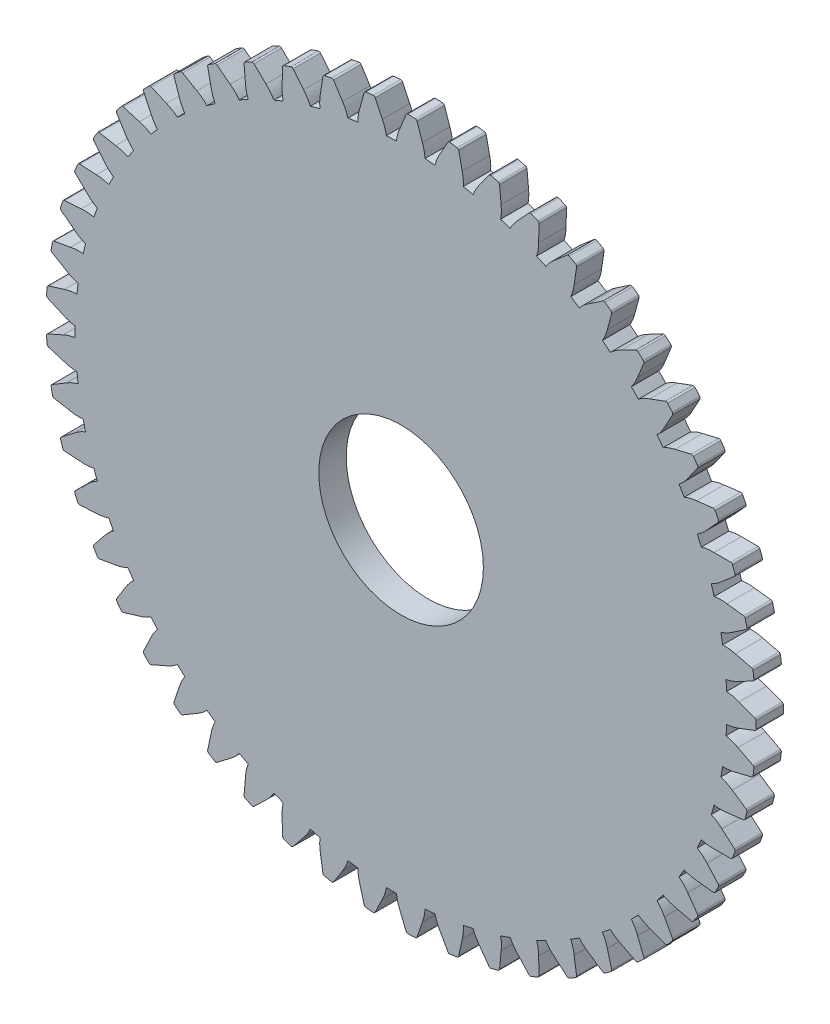
from build123d import *

# Parameters (mm, degrees)
BOSS_EXTRUDE1_DEPTH = 2
SKETCH2_R           = 6
CUT_EXTRUDE1_DEPTH  = 2


with BuildPart() as part:
    # Model → Boss-Extrude1 (new body)
    with BuildSketch(Plane.XY):
        with BuildLine():
            ThreePointArc((51.106924934, 28.354959457), (51.098148662, 28.539052367), (51.087944311, 28.723071642))
            ThreePointArc((51.087944311, 28.723071642), (51.076312495, 28.907006204), (51.063253916, 29.09084498))
            ThreePointArc((51.063253916, 29.09084498), (51.512091444, 29.214258003), (51.935275498, 29.408168181))
            ThreePointArc((51.935275498, 29.408168181), (52.475437041, 29.68664148), (53.015561208, 29.965187267))
            ThreePointArc((53.015561208, 29.965187267), (53.077986235, 30.026563656), (53.094727217, 30.112492026))
            ThreePointArc((53.094727217, 30.112492026), (53.08007401, 30.244113409), (53.064747207, 30.375658056))
            ThreePointArc((53.064747207, 30.375658056), (53.048747209, 30.507122519), (53.032074435, 30.638503353))
            ThreePointArc((53.032074435, 30.638503353), (52.995618443, 30.718095475), (52.920523428, 30.763091964))
            ThreePointArc((52.920523428, 30.763091964), (52.330083843, 30.906977222), (51.739624954, 31.05078324))
            ThreePointArc((51.739624954, 31.05078324), (51.282733561, 31.139868347), (50.817465202, 31.154402961))
            ThreePointArc((50.817465202, 31.154402961), (50.786977278, 31.336165742), (50.755080007, 31.517686503))
            ThreePointArc((50.755080007, 31.517686503), (50.72177531, 31.698954314), (50.687065192, 31.879958264))
            ThreePointArc((50.687065192, 31.879958264), (51.118155923, 32.055590501), (51.515435318, 32.298190962))
            ThreePointArc((51.515435318, 32.298190962), (52.018869599, 32.638596301), (52.522258193, 32.979069201))
            ThreePointArc((52.522258193, 32.979069201), (52.576985884, 33.047398001), (52.583446342, 33.134703256))
            ThreePointArc((52.583446342, 33.134703256), (52.553328706, 33.26366772), (52.522551278, 33.392476318))
            ThreePointArc((52.522551278, 33.392476318), (52.491114863, 33.521125675), (52.459020286, 33.649612418))
            ThreePointArc((52.459020286, 33.649612418), (52.413406562, 33.724334124), (52.333516756, 33.760133061))
            ThreePointArc((52.333516756, 33.760133061), (51.730203644, 33.833175241), (51.126880735, 33.906136453))
            ThreePointArc((51.126880735, 33.906136453), (50.662659841, 33.940558286), (50.198938101, 33.899962119))
            ThreePointArc((50.198938101, 33.899962119), (50.147166507, 34.076843222), (50.094024085, 34.253317314))
            ThreePointArc((50.094024085, 34.253317314), (50.039514032, 34.429373772), (49.98363963, 34.605001997))
            ThreePointArc((49.98363963, 34.605001997), (50.390931995, 34.830387955), (50.756729797, 35.118273121))
            ThreePointArc((50.756729797, 35.118273121), (51.216369703, 35.515831957), (51.675956251, 35.913452474))
            ThreePointArc((51.675956251, 35.913452474), (51.72221835, 35.987774499), (51.718307593, 36.075231066))
            ThreePointArc((51.718307593, 36.075231066), (51.673148314, 36.199728233), (51.627352308, 36.323992592))
            ThreePointArc((51.627352308, 36.323992592), (51.580920776, 36.448020886), (51.533854933, 36.571809865))
            ThreePointArc((51.533854933, 36.571809865), (51.479723794, 36.640612227), (51.396160672, 36.666711074))
            ThreePointArc((51.396160672, 36.666711074), (50.788443227, 36.667884823), (50.18072563, 36.668977014))
            ThreePointArc((50.18072563, 36.668977014), (49.715691878, 36.648252367), (49.260026394, 36.5530953))
            ThreePointArc((49.260026394, 36.5530953), (49.187697892, 36.7226117), (49.11405632, 36.891561815))
            ThreePointArc((49.11405632, 36.891561815), (49.039106112, 37.059935472), (48.96285178, 37.227722537))
            ThreePointArc((48.96285178, 37.227722537), (49.340628287, 37.499698293), (49.669809499, 37.828826886))
            ThreePointArc((49.669809499, 37.828826886), (50.079202692, 38.277958364), (50.488535606, 38.727144779))
            ThreePointArc((50.488535606, 38.727144779), (50.525682695, 38.80641671), (50.511455622, 38.89279689))
            ThreePointArc((50.511455622, 38.89279689), (50.451888637, 39.011079092), (50.391716929, 39.129054813))
            ThreePointArc((50.391716929, 39.129054813), (50.330942075, 39.24672096), (50.269565668, 39.36407445))
            ThreePointArc((50.269565668, 39.36407445), (50.207676997, 39.425991633), (50.121613603, 39.442024019))
            ThreePointArc((50.121613603, 39.442024019), (49.518022845, 39.37131286), (48.914441582, 39.300520698))
            ThreePointArc((48.914441582, 39.300520698), (48.455123028, 39.224940499), (48.013910344, 39.076558328))
            ThreePointArc((48.013910344, 39.076558328), (47.922040266, 39.236330388), (47.828933312, 39.395384836))
            ThreePointArc((47.828933312, 39.395384836), (47.734595086, 39.553712096), (47.639031268, 39.711302638))
            ThreePointArc((47.639031268, 39.711302638), (47.981988763, 40.026050247), (48.269932401, 40.391802024))
            ThreePointArc((48.269932401, 40.391802024), (48.623331898, 40.886201322), (48.976665043, 41.380648044))
            ThreePointArc((48.976665043, 41.380648044), (49.004175657, 41.463757076), (48.979831984, 41.547848281))
            ThreePointArc((48.979831984, 41.547848281), (48.906693483, 41.658255095), (48.832990752, 41.768286057))
            ThreePointArc((48.832990752, 41.768286057), (48.758725723, 41.877938282), (48.683900341, 41.987208897))
            ThreePointArc((48.683900341, 41.987208897), (48.615122919, 42.04137172), (48.527767395, 42.047112586))
            ThreePointArc((48.527767395, 42.047112586), (47.936776416, 41.905509149), (47.345804445, 41.7638264))
            ThreePointArc((47.345804445, 41.7638264), (46.898648914, 41.634451629), (46.478082689, 41.434927316))
            ThreePointArc((46.478082689, 41.434927316), (46.367960691, 41.582712185), (46.256695371, 41.72963819))
            ThreePointArc((46.256695371, 41.72963819), (46.144293429, 41.875696486), (46.030761631, 42.020878279))
            ThreePointArc((46.030761631, 42.020878279), (46.334085742, 42.373979376), (46.576749709, 42.771219983))
            ThreePointArc((46.576749709, 42.771219983), (46.869194557, 43.303946819), (47.161567908, 43.836712898))
            ThreePointArc((47.161567908, 43.836712898), (47.179055859, 43.922492363), (47.144937319, 44.003114137))
            ThreePointArc((47.144937319, 44.003114137), (47.059254006, 44.104095694), (46.973054877, 44.204637303))
            ThreePointArc((46.973054877, 44.204637303), (46.88634219, 44.304736329), (46.799118219, 44.404390149))
            ThreePointArc((46.799118219, 44.404390149), (46.72441753, 44.450038284), (46.636996155, 44.445407041))
            ThreePointArc((46.636996155, 44.445407041), (46.066901173, 44.234899128), (45.496834446, 44.024314708))
            ThreePointArc((45.496834446, 44.024314708), (45.06811902, 43.842961503), (44.674103083, 43.595095931))
            ThreePointArc((44.674103083, 43.595095931), (44.547275035, 43.728819035), (44.419413271, 43.861554078))
            ThreePointArc((44.419413271, 43.861554078), (44.29052549, 43.99329307), (44.16061945, 44.124028081))
            ThreePointArc((44.16061945, 44.124028081), (44.420052172, 44.510525899), (44.614029997, 44.933678949))
            ThreePointArc((44.614029997, 44.933678949), (44.841414911, 45.497255007), (45.068724188, 46.060861575))
            ThreePointArc((45.068724188, 46.060861575), (45.075943983, 46.148107318), (45.032529525, 46.224127907))
            ThreePointArc((45.032529525, 46.224127907), (44.935504206, 46.314266647), (44.838018725, 46.40390752))
            ThreePointArc((44.838018725, 46.40390752), (44.740075637, 46.493048176), (44.641677509, 46.581686279))
            ThreePointArc((44.641677509, 46.581686279), (44.562102188, 46.618178928), (44.475842167, 46.603240588))
            ThreePointArc((44.475842167, 46.603240588), (43.934646065, 46.326783268), (43.393487069, 46.05025332))
            ThreePointArc((43.393487069, 46.05025332), (42.989229974, 45.819467484), (42.627295444, 45.526740142))
            ThreePointArc((42.627295444, 45.526740142), (42.485541734, 45.644524301), (42.342878426, 45.761205073))
            ThreePointArc((42.342878426, 45.761205073), (42.199314107, 45.876775435), (42.054857421, 45.99122843))
            ThreePointArc((42.054857421, 45.99122843), (42.266756887, 46.405697388), (42.409325548, 46.84882274))
            ThreePointArc((42.409325548, 46.84882274), (42.568458541, 47.435336646), (42.72751282, 48.021871902))
            ThreePointArc((42.72751282, 48.021871902), (42.72436311, 48.109359184), (42.672262177, 48.179711426))
            ThreePointArc((42.672262177, 48.179711426), (42.565256875, 48.257741999), (42.457853525, 48.335223774))
            ThreePointArc((42.457853525, 48.335223774), (42.350054943, 48.412154721), (42.241863952, 48.488532824))
            ThreePointArc((42.241863952, 48.488532824), (42.158531061, 48.515357708), (42.074643296, 48.490321973))
            ThreePointArc((42.074643296, 48.490321973), (41.569943281, 48.151796101), (41.065288701, 47.8132025))
            ThreePointArc((41.065288701, 47.8132025), (40.691164821, 47.536223759), (40.366392466, 47.202743898))
            ThreePointArc((40.366392466, 47.202743898), (40.211703006, 47.30293568), (40.056240832, 47.40192424))
            ThreePointArc((40.056240832, 47.40192424), (39.900015305, 47.499703617), (39.743035827, 47.596267927))
            ThreePointArc((39.743035827, 47.596267927), (39.904427434, 48.032889789), (39.993585578, 48.489766934))
            ThreePointArc((39.993585578, 48.489766934), (40.082232772, 49.090985319), (40.170799281, 49.692215595))
            ThreePointArc((40.170799281, 49.692215595), (40.15732428, 49.778716286), (40.097268256, 49.84241259))
            ThreePointArc((40.097268256, 49.84241259), (39.98178509, 49.907239617), (39.865971579, 49.97147462))
            ThreePointArc((39.865971579, 49.97147462), (39.749830757, 50.035115916), (39.633365668, 50.098161837))
            ThreePointArc((39.633365668, 50.098161837), (39.547445018, 50.114942394), (39.467107109, 50.08016071))
            ThreePointArc((39.467107109, 50.08016071), (39.005988064, 49.684318448), (38.544922145, 49.288414306))
            ThreePointArc((38.544922145, 49.288414306), (38.206183359, 48.969130834), (37.92313227, 48.59957978))
            ThreePointArc((37.92313227, 48.59957978), (37.75767856, 48.680772712), (37.59159987, 48.760679477))
            ThreePointArc((37.59159987, 48.760679477), (37.424906197, 48.839295262), (37.257607577, 48.916615335))
            ThreePointArc((37.257607577, 48.916615335), (37.366225739, 49.369260887), (37.400721782, 49.833476272))
            ThreePointArc((37.400721782, 49.833476272), (37.417638766, 50.440959348), (37.434474223, 51.048444688))
            ThreePointArc((37.434474223, 51.048444688), (37.410863091, 51.132744507), (37.34369503, 51.188890717))
            ThreePointArc((37.34369503, 51.188890717), (37.221355132, 51.239604169), (37.098757227, 51.289690682))
            ThreePointArc((37.098757227, 51.289690682), (36.975904529, 51.339148942), (36.852800256, 51.387977654))
            ThreePointArc((36.852800256, 51.387977654), (36.765497985, 51.394478323), (36.6898377, 51.350438949))
            ThreePointArc((36.6898377, 51.350438949), (36.278772724, 50.902837054), (35.867767822, 50.455179997))
            ThreePointArc((35.867767822, 50.455179997), (35.569169279, 50.098073835), (35.331812873, 49.697639274))
            ThreePointArc((35.331812873, 49.697639274), (35.157917522, 49.758693586), (34.983553696, 49.818396839))
            ThreePointArc((34.983553696, 49.818396839), (34.808731892, 49.876745439), (34.633462634, 49.933735872))
            ThreePointArc((34.633462634, 49.933735872), (34.687782591, 50.396050962), (34.667132284, 50.861088021))
            ThreePointArc((34.667132284, 50.861088021), (34.612081579, 51.466308056), (34.556949653, 52.071520698))
            ThreePointArc((34.556949653, 52.071520698), (34.523533838, 52.152436261), (34.450196633, 52.200244206))
            ThreePointArc((34.450196633, 52.200244206), (34.322717386, 52.236132178), (34.195056093, 52.271367096))
            ThreePointArc((34.195056093, 52.271367096), (34.067216101, 52.305948035), (33.939200759, 52.33987409))
            ThreePointArc((33.939200759, 52.33987409), (33.8517424, 52.336003615), (33.781821844, 52.283324768))
            ThreePointArc((33.781821844, 52.283324768), (33.426581388, 51.790246589), (33.071407109, 51.297120741))
            ThreePointArc((33.071407109, 51.297120741), (32.817140479, 50.907204876), (32.628810721, 50.481508032))
            ThreePointArc((32.628810721, 50.481508032), (32.448914837, 50.521566656), (32.268713561, 50.560228295))
            ThreePointArc((32.268713561, 50.560228295), (32.088217741, 50.597490622), (31.907438241, 50.633351393))
            ThreePointArc((31.907438241, 50.633351393), (31.90669746, 51.098846132), (31.831190688, 51.558176763))
            ThreePointArc((31.831190688, 51.558176763), (31.704945086, 52.152637795), (31.578619707, 52.74708188))
            ThreePointArc((31.578619707, 52.74708188), (31.535868294, 52.823477311), (31.457391439, 52.862275873))
            ThreePointArc((31.457391439, 52.862275873), (31.326562372, 52.882834576), (31.195629777, 52.902723276))
            ThreePointArc((31.195629777, 52.902723276), (31.064597084, 52.921941454), (30.933467727, 52.940488605))
            ThreePointArc((30.933467727, 52.940488605), (30.847081003, 52.926301319), (30.783881707, 52.865722494))
            ThreePointArc((30.783881707, 52.865722494), (30.48945257, 52.334089769), (30.195094783, 51.802417535))
            ThreePointArc((30.195094783, 51.802417535), (29.988729411, 51.385165531), (29.852070037, 50.940182255))
            ThreePointArc((29.852070037, 50.940182255), (29.668698965, 50.958682855), (29.48518987, 50.975760155))
            ThreePointArc((29.48518987, 50.975760155), (29.301553799, 50.991413128), (29.117801806, 51.005640832))
            ThreePointArc((29.117801806, 51.005640832), (29.062010685, 51.467780693), (28.932707398, 51.914956901))
            ThreePointArc((28.932707398, 51.914956901), (28.737039111, 52.490314001), (28.541293611, 53.065644836))
            ThreePointArc((28.541293611, 53.065644836), (28.489806736, 53.13644771), (28.407291874, 53.165692242))
            ThreePointArc((28.407291874, 53.165692242), (28.27494954, 53.170633077), (28.142583648, 53.174896367))
            ThreePointArc((28.142583648, 53.174896367), (28.010197666, 53.178482003), (27.877795063, 53.181389888))
            ThreePointArc((27.877795063, 53.181389888), (27.793692655, 53.15708495), (27.738101798, 53.08945654))
            ThreePointArc((27.738101798, 53.08945654), (27.50861712, 52.526732226), (27.279207962, 51.96397712))
            ThreePointArc((27.279207962, 51.96397712), (27.123640767, 51.525246281), (27.040570175, 51.067223162))
            ThreePointArc((27.040570175, 51.067223162), (26.856298042, 51.06390603), (26.672057193, 51.059159264))
            ThreePointArc((26.672057193, 51.059159264), (26.487858719, 51.05298315), (26.303713709, 51.045378059))
            ThreePointArc((26.303713709, 51.045378059), (26.193655434, 51.497675613), (26.012370766, 51.926420024))
            ThreePointArc((26.012370766, 51.926420024), (25.750026547, 52.474596439), (25.487608763, 53.022737641))
            ThreePointArc((25.487608763, 53.022737641), (25.42810919, 53.08695404), (25.342714648, 53.106234014))
            ThreePointArc((25.342714648, 53.106234014), (25.210716844, 53.095487622), (25.078775783, 53.084065655))
            ThreePointArc((25.078775783, 53.084065655), (24.946894921, 53.071968413), (24.815077714, 53.059196213))
            ThreePointArc((24.815077714, 53.059196213), (24.734440235, 53.02511481), (24.687238192, 52.95138617))
            ThreePointArc((24.687238192, 52.95138617), (24.525919433, 52.365469684), (24.364679307, 51.779531553))
            ThreePointArc((24.364679307, 51.779531553), (24.262094111, 51.325480699), (24.23377843, 50.860847378))
            ThreePointArc((24.23377843, 50.860847378), (24.051192013, 50.835759079), (23.868805748, 50.80925488))
            ThreePointArc((23.868805748, 50.80925488), (23.686630614, 50.781336378), (23.504677578, 50.752005253))
            ThreePointArc((23.504677578, 50.752005253), (23.341897125, 51.188111232), (23.111175916, 51.592405215))
            ThreePointArc((23.111175916, 51.592405215), (22.785838503, 52.10570575), (22.460432207, 52.618962618))
            ThreePointArc((22.460432207, 52.618962618), (22.393755178, 52.675691085), (22.306679708, 52.684735851))
            ThreePointArc((22.306679708, 52.684735851), (22.176879395, 52.658453088), (22.047215327, 52.631506203))
            ThreePointArc((22.047215327, 52.631506203), (21.917690903, 52.603895903), (21.788309518, 52.575622911))
            ThreePointArc((21.788309518, 52.575622911), (21.71226894, 52.532243471), (21.674118324, 52.453449591))
            ThreePointArc((21.674118324, 52.453449591), (21.583230047, 51.852565915), (21.492422411, 51.251670047))
            ThreePointArc((21.492422411, 51.251670047), (21.444259284, 50.788673055), (21.471096004, 50.323951965))
            ThreePointArc((21.471096004, 50.323951965), (21.292758417, 50.277444684), (21.114787039, 50.229555114))
            ThreePointArc((21.114787039, 50.229555114), (20.937192585, 50.180286138), (20.759985745, 50.129640723))
            ThreePointArc((20.759985745, 50.129640723), (20.546768195, 50.543433156), (20.269849265, 50.91760131))
            ThreePointArc((20.269849265, 50.91760131), (19.886085682, 51.388820349), (19.502258864, 51.859987883))
            ThreePointArc((19.502258864, 51.859987883), (19.429340379, 51.908432074), (19.341806331, 51.907114664))
            ThreePointArc((19.341806331, 51.907114664), (19.216025619, 51.865664483), (19.090458744, 51.823570955))
            ThreePointArc((19.090458744, 51.823570955), (18.965108998, 51.780835185), (18.839979664, 51.737458291))
            ThreePointArc((18.839979664, 51.737458291), (18.769603432, 51.685389767), (18.741039793, 51.602636739))
            ThreePointArc((18.741039793, 51.602636739), (18.72185787, 50.995220963), (18.702757464, 50.387802619))
            ThreePointArc((18.702757464, 50.387802619), (18.709692512, 49.922358953), (18.791304905, 49.46407376))
            ThreePointArc((18.791304905, 49.46407376), (18.619719616, 49.396800356), (18.448661453, 49.32819768))
            ThreePointArc((18.448661453, 49.32819768), (18.278140715, 49.258269859), (18.108167666, 49.187021104))
            ThreePointArc((18.108167666, 49.187021104), (17.847506128, 49.572691252), (17.528276811, 49.911481075))
            ThreePointArc((17.528276811, 49.911481075), (17.091474257, 50.334003738), (16.654615004, 50.756467777))
            ThreePointArc((16.654615004, 50.756467777), (16.576478679, 50.795947643), (16.489714838, 50.78428655))
            ThreePointArc((16.489714838, 50.78428655), (16.369719414, 50.728250819), (16.250012416, 50.67160155))
            ThreePointArc((16.250012416, 50.67160155), (16.130596982, 50.614340226), (16.011476242, 50.556468347))
            ThreePointArc((16.011476242, 50.556468347), (15.947752284, 50.496441668), (15.929176593, 50.410891163))
            ThreePointArc((15.929176593, 50.410891163), (15.981970296, 49.805470073), (16.034845247, 49.200056074))
            ThreePointArc((16.034845247, 49.200056074), (16.096781117, 48.738699543), (16.232023523, 48.293283566))
            ThreePointArc((16.232023523, 48.293283566), (16.069599214, 48.206188412), (15.907855548, 48.117835659))
            ThreePointArc((15.907855548, 48.117835659), (15.746802264, 48.028230627), (15.586449056, 47.937378709))
            ThreePointArc((15.586449056, 47.937378709), (15.282002644, 48.289512608), (14.92494422, 48.588168235))
            ThreePointArc((14.92494422, 48.588168235), (14.441234447, 48.956063228), (13.957475306, 49.323893303))
            ThreePointArc((13.957475306, 49.323893303), (13.875218003, 49.353854633), (13.790442344, 49.332013553))
            ThreePointArc((13.790442344, 49.332013553), (13.677916679, 49.262178893), (13.565749982, 49.191769114))
            ThreePointArc((13.565749982, 49.191769114), (13.453945192, 49.120786059), (13.34250524, 49.04923159))
            ThreePointArc((13.34250524, 49.04923159), (13.286328099, 48.982089397), (13.278001119, 48.894942357))
            ThreePointArc((13.278001119, 48.894942357), (13.40202934, 48.300014739), (13.526137401, 47.70510377))
            ThreePointArc((13.526137401, 47.70510377), (13.642204649, 47.254310808), (13.829178561, 46.828016711))
            ThreePointArc((13.829178561, 46.828016711), (13.678195312, 46.722322432), (13.52803667, 46.615459883))
            ThreePointArc((13.52803667, 46.615459883), (13.378711674, 46.507435497), (13.230229315, 46.398255777))
            ThreePointArc((13.230229315, 46.398255777), (12.88627179, 46.71191024), (12.496396577, 46.966239199))
            ThreePointArc((12.496396577, 46.966239199), (11.972569809, 47.274342085), (11.448701698, 47.582374668))
            ThreePointArc((11.448701698, 47.582374668), (11.363478129, 47.60239687), (11.281880716, 47.570682405))
            ThreePointArc((11.281880716, 47.570682405), (11.178404425, 47.488029141), (11.075352603, 47.404847249))
            ThreePointArc((11.075352603, 47.404847249), (10.972727951, 47.321138911), (10.870533159, 47.236906319))
            ThreePointArc((10.870533159, 47.236906319), (10.822691441, 47.163591143), (10.824730064, 47.076070921))
            ThreePointArc((10.824730064, 47.076070921), (11.018251718, 46.499988253), (11.211850683, 45.923931562))
            ThreePointArc((11.211850683, 45.923931562), (11.380419979, 45.490030313), (11.616500694, 45.088842332))
            ThreePointArc((11.616500694, 45.088842332), (11.47907798, 44.966032642), (11.342612259, 44.842160412))
            ThreePointArc((11.342612259, 44.842160412), (11.207111748, 44.717233099), (11.072584603, 44.591258222))
            ThreePointArc((11.072584603, 44.591258222), (10.693944376, 44.862030227), (10.276725367, 45.068462298))
            ThreePointArc((10.276725367, 45.068462298), (9.720134984, 45.312447986), (9.163511862, 45.556358975))
            ThreePointArc((9.163511862, 45.556358975), (9.07651838, 45.566160982), (8.999244662, 45.525018333))
            ThreePointArc((8.999244662, 45.525018333), (8.906270324, 45.430706734), (8.813779999, 45.335920423))
            ThreePointArc((8.813779999, 45.335920423), (8.721776111, 45.240661883), (8.63026107, 45.144933609))
            ThreePointArc((8.63026107, 45.144933609), (8.591426366, 45.066474633), (8.603801974, 44.979809822))
            ThreePointArc((8.603801974, 44.979809822), (8.864100442, 44.430659043), (9.124472606, 43.881543201))
            ThreePointArc((9.124472606, 43.881543201), (9.343177607, 43.470624689), (9.625051069, 43.100174622))
            ThreePointArc((9.625051069, 43.100174622), (9.503118003, 42.961973502), (9.382260884, 42.822830486))
            ThreePointArc((9.382260884, 42.822830486), (9.262486987, 42.68275395), (9.143803524, 42.541752327))
            ThreePointArc((9.143803524, 42.541752327), (8.735795872, 42.765840829), (8.297089908, 42.921478158))
            ThreePointArc((8.297089908, 42.921478158), (7.715549218, 43.097921624), (7.133984854, 43.274287044))
            ThreePointArc((7.133984854, 43.274287044), (7.046442657, 43.273731256), (6.974577387, 43.223737976))
            ThreePointArc((6.974577387, 43.223737976), (6.893410159, 43.119091972), (6.812779692, 43.014031832))
            ThreePointArc((6.812779692, 43.014031832), (6.7326881, 42.908560311), (6.653137481, 42.802680171))
            ThreePointArc((6.653137481, 42.802680171), (6.623854946, 42.720178787), (6.646393813, 42.635585971))
            ThreePointArc((6.646393813, 42.635585971), (6.969815075, 42.121075953), (7.293305384, 41.606609345))
            ThreePointArc((7.293305384, 41.606609345), (7.559075951, 41.224441964), (7.882785274, 40.889930119))
            ThreePointArc((7.882785274, 40.889930119), (7.778053529, 40.738277609), (7.67450158, 40.585817069))
            ThreePointArc((7.67450158, 40.585817069), (7.572135661, 40.432557678), (7.470961935, 40.278508662))
            ThreePointArc((7.470961935, 40.278508662), (7.039314391, 40.45276795), (6.585279942, 40.55542573))
            ThreePointArc((6.585279942, 40.55542573), (5.986952502, 40.661850095), (5.388610785, 40.768194162))
            ThreePointArc((5.388610785, 40.768194162), (5.301748773, 40.757288382), (5.236300782, 40.699146266))
            ThreePointArc((5.236300782, 40.699146266), (5.168080074, 40.585634857), (5.100441341, 40.471775704))
            ThreePointArc((5.100441341, 40.471775704), (5.033386355, 40.35757179), (4.966916874, 40.243026109))
            ThreePointArc((4.966916874, 40.243026109), (4.94759757, 40.157640456), (4.9799833, 40.076307132))
            ThreePointArc((4.9799833, 40.076307132), (5.361987231, 39.603660469), (5.744054589, 39.131065076))
            ThreePointArc((5.744054589, 39.131065076), (6.053159886, 38.78301362), (6.414160901, 38.489135809))
            ThreePointArc((6.414160901, 38.489135809), (6.328100681, 38.326160778), (6.243307545, 38.162522927))
            ThreePointArc((6.243307545, 38.162522927), (6.159786597, 37.998232107), (6.077542865, 37.833298209))
            ThreePointArc((6.077542865, 37.833298209), (5.628314815, 37.955282064), (5.165325529, 38.003519205))
            ThreePointArc((5.165325529, 38.003519205), (4.558610545, 38.038430504), (3.951890881, 38.07326038))
            ThreePointArc((3.951890881, 38.07326038), (3.866928406, 38.052157701), (3.808816441, 37.986682937))
            ThreePointArc((3.808816441, 37.986682937), (3.754499922, 37.865899574), (3.700802421, 37.74483974))
            ThreePointArc((3.700802421, 37.74483974), (3.647725347, 37.623506607), (3.595270089, 37.501903354))
            ThreePointArc((3.595270089, 37.501903354), (3.586185219, 37.41483206), (3.627963186, 37.337899969))
            ThreePointArc((3.627963186, 37.337899969), (4.063187287, 36.913751584), (4.498468307, 36.489661611))
            ThreePointArc((4.498468307, 36.489661611), (4.846569173, 36.180611958), (5.239794217, 35.931493582))
            ThreePointArc((5.239794217, 35.931493582), (5.17361362, 35.759483842), (5.108769606, 35.586965797))
            ThreePointArc((5.108769606, 35.586965797), (5.045266079, 35.413949831), (4.983106863, 35.240446361))
            ThreePointArc((4.983106863, 35.240446361), (4.522604485, 35.308442397), (4.057159717, 35.301581755))
            ThreePointArc((4.057159717, 35.301581755), (3.450574137, 35.26448991), (2.84399354, 35.22731666))
            ThreePointArc((2.84399354, 35.22731666), (2.762123289, 35.196313317), (2.712163114, 35.124425028))
            ThreePointArc((2.712163114, 35.124425028), (2.672513269, 34.998065245), (2.633510796, 34.871504145))
            ThreePointArc((2.633510796, 34.871504145), (2.595156719, 34.744745043), (2.557452043, 34.617791263))
            ThreePointArc((2.557452043, 34.617791263), (2.558729136, 34.530256617), (2.60931287, 34.458805718))
            ThreePointArc((2.60931287, 34.458805718), (3.091647549, 34.089109724), (3.574031839, 33.719478465))
            ThreePointArc((3.574031839, 33.719478465), (3.956241701, 33.453768995), (4.376170757, 33.25290713))
            ThreePointArc((4.376170757, 33.25290713), (4.330798812, 33.07427732), (4.286814188, 32.895300855))
            ThreePointArc((4.286814188, 32.895300855), (4.244219533, 32.715988508), (4.203017413, 32.536351075))
            ThreePointArc((4.203017413, 32.536351075), (3.73770515, 32.549404777), (3.276338723, 32.48754266))
            ThreePointArc((3.276338723, 32.48754266), (2.678397679, 32.37896836), (2.080471212, 32.270313814))
            ThreePointArc((2.080471212, 32.270313814), (2.002842464, 32.229845027), (1.961735411, 32.152552367))
            ThreePointArc((1.961735411, 32.152552367), (1.937308836, 32.022389978), (1.913548901, 31.892104252))
            ThreePointArc((1.913548901, 31.892104252), (1.890456228, 31.761698602), (1.868031423, 31.631176446))
            ThreePointArc((1.868031423, 31.631176446), (1.879652552, 31.544407244), (1.938331969, 31.47944055))
            ThreePointArc((1.938331969, 31.47944055), (2.461006305, 31.169386669), (2.983722247, 30.859402935))
            ThreePointArc((2.983722247, 30.859402935), (3.394675716, 30.640763627), (3.8354139, 30.490977933))
            ThreePointArc((3.8354139, 30.490977933), (3.81148753, 30.308235625), (3.788979744, 30.125313177))
            ThreePointArc((3.788979744, 30.125313177), (3.767891897, 29.942221602), (3.748225259, 29.758971921))
            ThreePointArc((3.748225259, 29.758971921), (3.284635076, 29.716900044), (2.833823564, 29.600904861))
            ThreePointArc((2.833823564, 29.600904861), (2.252920838, 29.42237225), (1.672042076, 29.243761681))
            ThreePointArc((1.672042076, 29.243761681), (1.59974457, 29.194395542), (1.568067691, 29.11278353))
            ThreePointArc((1.568067691, 29.11278353), (1.559207282, 28.98064573), (1.551023422, 28.848464304))
            ThreePointArc((1.551023422, 28.848464304), (1.543516324, 28.716242715), (1.536686186, 28.583984429))
            ThreePointArc((1.536686186, 28.583984429), (1.558488216, 28.499198719), (1.624439584, 28.441628221))
            ThreePointArc((1.624439584, 28.441628221), (2.180116375, 28.19556893), (2.735826183, 27.949584214))
            ThreePointArc((2.735826183, 27.949584214), (3.169754373, 27.781084284), (3.625114687, 27.684477424))
            ThreePointArc((3.625114687, 27.684477424), (3.622969766, 27.500187919), (3.622254779, 27.315887319))
            ThreePointArc((3.622254779, 27.315887319), (3.622969766, 27.13158672), (3.625114687, 26.947297215))
            ThreePointArc((3.625114687, 26.947297215), (3.169754373, 26.850690355), (2.735826183, 26.682190425))
            ThreePointArc((2.735826183, 26.682190425), (2.180116375, 26.436205709), (1.624439584, 26.190146417))
            ThreePointArc((1.624439584, 26.190146417), (1.558488216, 26.132575919), (1.536686186, 26.047790209))
            ThreePointArc((1.536686186, 26.047790209), (1.543516324, 25.915531923), (1.551023422, 25.783310335))
            ThreePointArc((1.551023422, 25.783310335), (1.559207282, 25.651128908), (1.568067691, 25.518991108))
            ThreePointArc((1.568067691, 25.518991108), (1.59974457, 25.437379096), (1.672042076, 25.388012958))
            ThreePointArc((1.672042076, 25.388012958), (2.252920838, 25.209402389), (2.833823565, 25.030869777))
            ThreePointArc((2.833823565, 25.030869777), (3.284635076, 24.914874595), (3.748225259, 24.872802717))
            ThreePointArc((3.748225259, 24.872802717), (3.767891897, 24.689553036), (3.788979744, 24.506461461))
            ThreePointArc((3.788979744, 24.506461461), (3.81148753, 24.323539014), (3.8354139, 24.140796706))
            ThreePointArc((3.8354139, 24.140796706), (3.394675716, 23.991011012), (2.983722247, 23.772371703))
            ThreePointArc((2.983722247, 23.772371703), (2.461006305, 23.46238797), (1.938331969, 23.152334089))
            ThreePointArc((1.938331969, 23.152334089), (1.879652552, 23.087367395), (1.868031423, 23.000598192))
            ThreePointArc((1.868031423, 23.000598192), (1.890456228, 22.870076037), (1.913548901, 22.739670387))
            ThreePointArc((1.913548901, 22.739670387), (1.937308836, 22.609384661), (1.961735411, 22.479222272))
            ThreePointArc((1.961735411, 22.479222272), (2.002842464, 22.401929612), (2.080471212, 22.361460824))
            ThreePointArc((2.080471212, 22.361460824), (2.678397679, 22.252806279), (3.276338723, 22.144231978))
            ThreePointArc((3.276338723, 22.144231978), (3.73770515, 22.082369862), (4.203017413, 22.095423564))
            ThreePointArc((4.203017413, 22.095423564), (4.244219533, 21.91578613), (4.286814188, 21.736473784))
            ThreePointArc((4.286814188, 21.736473784), (4.330798812, 21.557497318), (4.376170757, 21.378867509))
            ThreePointArc((4.376170757, 21.378867509), (3.956241701, 21.178005644), (3.574031839, 20.912296174))
            ThreePointArc((3.574031839, 20.912296174), (3.091647549, 20.542664914), (2.60931287, 20.17296892))
            ThreePointArc((2.60931287, 20.17296892), (2.558729136, 20.101518021), (2.557452043, 20.013983376))
            ThreePointArc((2.557452043, 20.013983376), (2.595156719, 19.887029595), (2.633510796, 19.760270494))
            ThreePointArc((2.633510796, 19.760270494), (2.672513269, 19.633709393), (2.712163114, 19.50734961))
            ThreePointArc((2.712163114, 19.50734961), (2.762123289, 19.435461321), (2.84399354, 19.404457979))
            ThreePointArc((2.84399354, 19.404457979), (3.450574137, 19.367284729), (4.057159717, 19.330192884))
            ThreePointArc((4.057159717, 19.330192884), (4.522604485, 19.323332241), (4.983106863, 19.391328278))
            ThreePointArc((4.983106863, 19.391328278), (5.045266079, 19.217824808), (5.108769606, 19.044808842))
            ThreePointArc((5.108769606, 19.044808842), (5.17361362, 18.872290796), (5.239794217, 18.700281056))
            ThreePointArc((5.239794217, 18.700281056), (4.846569173, 18.45116268), (4.498468307, 18.142113027))
            ThreePointArc((4.498468307, 18.142113027), (4.063187287, 17.718023054), (3.627963186, 17.293874669))
            ThreePointArc((3.627963186, 17.293874669), (3.586185219, 17.216942578), (3.595270089, 17.129871284))
            ThreePointArc((3.595270089, 17.129871284), (3.647725347, 17.008268032), (3.700802421, 16.886934899))
            ThreePointArc((3.700802421, 16.886934899), (3.754499922, 16.765875064), (3.808816441, 16.645091702))
            ThreePointArc((3.808816441, 16.645091702), (3.866928406, 16.579616938), (3.951890881, 16.558514259))
            ThreePointArc((3.951890881, 16.558514259), (4.558610545, 16.593344135), (5.165325529, 16.628255434))
            ThreePointArc((5.165325529, 16.628255434), (5.628314815, 16.676492575), (6.077542865, 16.79847643))
            ThreePointArc((6.077542865, 16.79847643), (6.159786597, 16.633542532), (6.243307545, 16.469251712))
            ThreePointArc((6.243307545, 16.469251712), (6.328100681, 16.305613861), (6.414160901, 16.14263883))
            ThreePointArc((6.414160901, 16.14263883), (6.053159886, 15.848761019), (5.744054589, 15.500709562))
            ThreePointArc((5.744054589, 15.500709562), (5.361987231, 15.02811417), (4.9799833, 14.555467507))
            ThreePointArc((4.9799833, 14.555467507), (4.94759757, 14.474134182), (4.966916874, 14.38874853))
            ThreePointArc((4.966916874, 14.38874853), (5.033386355, 14.274202849), (5.100441341, 14.159998935))
            ThreePointArc((5.100441341, 14.159998935), (5.168080074, 14.046139782), (5.236300782, 13.932628373))
            ThreePointArc((5.236300782, 13.932628373), (5.301748773, 13.874486257), (5.388610785, 13.863580477))
            ThreePointArc((5.388610785, 13.863580477), (5.986952502, 13.969924543), (6.585279942, 14.076348909))
            ThreePointArc((6.585279942, 14.076348909), (7.039314391, 14.179006688), (7.470961935, 14.353265976))
            ThreePointArc((7.470961935, 14.353265976), (7.572135661, 14.19921696), (7.67450158, 14.045957569))
            ThreePointArc((7.67450158, 14.045957569), (7.778053529, 13.89349703), (7.882785274, 13.74184452))
            ThreePointArc((7.882785274, 13.74184452), (7.559075951, 13.407332674), (7.293305384, 13.025165294))
            ThreePointArc((7.293305384, 13.025165294), (6.969815075, 12.510698685), (6.646393813, 11.996188668))
            ThreePointArc((6.646393813, 11.996188668), (6.623854946, 11.911595851), (6.653137481, 11.829094467))
            ThreePointArc((6.653137481, 11.829094467), (6.7326881, 11.723214328), (6.812779692, 11.617742806))
            ThreePointArc((6.812779692, 11.617742806), (6.893410159, 11.512682667), (6.974577387, 11.408036663))
            ThreePointArc((6.974577387, 11.408036663), (7.046442657, 11.358043382), (7.133984854, 11.357487594))
            ThreePointArc((7.133984854, 11.357487594), (7.715549218, 11.533853015), (8.297089908, 11.710296481))
            ThreePointArc((8.297089908, 11.710296481), (8.735795872, 11.86593381), (9.143803524, 12.090022312))
            ThreePointArc((9.143803524, 12.090022312), (9.262486987, 11.949020689), (9.382260884, 11.808944153))
            ThreePointArc((9.382260884, 11.808944153), (9.503118003, 11.669801136), (9.625051069, 11.531600016))
            ThreePointArc((9.625051069, 11.531600016), (9.343177607, 11.161149949), (9.124472606, 10.750231437))
            ThreePointArc((9.124472606, 10.750231437), (8.864100442, 10.201115596), (8.603801974, 9.651964817))
            ThreePointArc((8.603801974, 9.651964817), (8.591426366, 9.565300005), (8.63026107, 9.486841029))
            ThreePointArc((8.63026107, 9.486841029), (8.721776111, 9.391112756), (8.813779999, 9.295854216))
            ThreePointArc((8.813779999, 9.295854216), (8.906270324, 9.201067904), (8.999244662, 9.106756306))
            ThreePointArc((8.999244662, 9.106756306), (9.07651838, 9.065613657), (9.163511862, 9.075415663))
            ThreePointArc((9.163511862, 9.075415663), (9.720134984, 9.319326653), (10.276725367, 9.563312341))
            ThreePointArc((10.276725367, 9.563312341), (10.693944376, 9.769744412), (11.072584603, 10.040516417))
            ThreePointArc((11.072584603, 10.040516417), (11.207111748, 9.91454154), (11.342612259, 9.789614226))
            ThreePointArc((11.342612259, 9.789614226), (11.47907798, 9.665741996), (11.616500694, 9.542932307))
            ThreePointArc((11.616500694, 9.542932307), (11.380419979, 9.141744325), (11.211850683, 8.707843077))
            ThreePointArc((11.211850683, 8.707843077), (11.018251718, 8.131786385), (10.824730064, 7.555703717))
            ThreePointArc((10.824730064, 7.555703717), (10.822691441, 7.468183496), (10.870533159, 7.394868319))
            ThreePointArc((10.870533159, 7.394868319), (10.972727951, 7.310635728), (11.075352603, 7.226927389))
            ThreePointArc((11.075352603, 7.226927389), (11.178404425, 7.143745498), (11.281880716, 7.061092234))
            ThreePointArc((11.281880716, 7.061092234), (11.363478129, 7.029377768), (11.448701698, 7.04939997))
            ThreePointArc((11.448701698, 7.04939997), (11.972569809, 7.357432554), (12.496396577, 7.665535439))
            ThreePointArc((12.496396577, 7.665535439), (12.88627179, 7.919864398), (13.230229315, 8.233518861))
            ThreePointArc((13.230229315, 8.233518861), (13.378711674, 8.124339142), (13.52803667, 8.016314756))
            ThreePointArc((13.52803667, 8.016314756), (13.678195312, 7.909452207), (13.829178561, 7.803757927))
            ThreePointArc((13.829178561, 7.803757927), (13.642204649, 7.37746383), (13.526137401, 6.926670868))
            ThreePointArc((13.526137401, 6.926670868), (13.40202934, 6.3317599), (13.278001119, 5.736832281))
            ThreePointArc((13.278001119, 5.736832281), (13.286328099, 5.649685241), (13.34250524, 5.582543048))
            ThreePointArc((13.34250524, 5.582543048), (13.453945192, 5.510988579), (13.565749982, 5.440005525))
            ThreePointArc((13.565749982, 5.440005525), (13.677916679, 5.369595745), (13.790442344, 5.299761085))
            ThreePointArc((13.790442344, 5.299761085), (13.875218003, 5.277920005), (13.957475306, 5.307881335))
            ThreePointArc((13.957475306, 5.307881335), (14.441234447, 5.67571141), (14.92494422, 6.043606404))
            ThreePointArc((14.92494422, 6.043606404), (15.282002644, 6.34226203), (15.586449056, 6.69439593))
            ThreePointArc((15.586449056, 6.69439593), (15.746802264, 6.603544012), (15.907855548, 6.513938979))
            ThreePointArc((15.907855548, 6.513938979), (16.069599214, 6.425586227), (16.232023523, 6.338491073))
            ThreePointArc((16.232023523, 6.338491073), (16.096781117, 5.893075096), (16.034845247, 5.431718565))
            ThreePointArc((16.034845247, 5.431718565), (15.981970296, 4.826304566), (15.929176593, 4.220883476))
            ThreePointArc((15.929176593, 4.220883476), (15.947752284, 4.135332971), (16.011476242, 4.075306291))
            ThreePointArc((16.011476242, 4.075306291), (16.130596982, 4.017434413), (16.250012416, 3.960173089))
            ThreePointArc((16.250012416, 3.960173089), (16.369719414, 3.903523819), (16.489714838, 3.847488089))
            ThreePointArc((16.489714838, 3.847488089), (16.576478679, 3.835826996), (16.654615004, 3.875306862))
            ThreePointArc((16.654615004, 3.875306862), (17.091474257, 4.297770901), (17.528276811, 4.720293563))
            ThreePointArc((17.528276811, 4.720293563), (17.847506128, 5.059083386), (18.108167666, 5.444753534))
            ThreePointArc((18.108167666, 5.444753534), (18.278140715, 5.37350478), (18.448661453, 5.303576959))
            ThreePointArc((18.448661453, 5.303576959), (18.619719616, 5.234974282), (18.791304905, 5.167700879))
            ThreePointArc((18.791304905, 5.167700879), (18.709692512, 4.709415686), (18.702757464, 4.24397202))
            ThreePointArc((18.702757464, 4.24397202), (18.72185787, 3.636553675), (18.741039793, 3.029137899))
            ThreePointArc((18.741039793, 3.029137899), (18.769603432, 2.946384871), (18.839979664, 2.894316348))
            ThreePointArc((18.839979664, 2.894316348), (18.965108998, 2.850939454), (19.090458744, 2.808203683))
            ThreePointArc((19.090458744, 2.808203683), (19.216025619, 2.766110156), (19.341806331, 2.724659975))
            ThreePointArc((19.341806331, 2.724659975), (19.429340379, 2.723342564), (19.502258864, 2.771786756))
            ThreePointArc((19.502258864, 2.771786756), (19.886085682, 3.242954289), (20.269849265, 3.714173329))
            ThreePointArc((20.269849265, 3.714173329), (20.546768195, 4.088341482), (20.759985745, 4.502133915))
            ThreePointArc((20.759985745, 4.502133915), (20.937192585, 4.4514885), (21.114787039, 4.402219525))
            ThreePointArc((21.114787039, 4.402219525), (21.292758417, 4.354329955), (21.471096004, 4.307822673))
            ThreePointArc((21.471096004, 4.307822673), (21.444259284, 3.843101583), (21.492422411, 3.380104592))
            ThreePointArc((21.492422411, 3.380104592), (21.583230047, 2.779208724), (21.674118324, 2.178325048))
            ThreePointArc((21.674118324, 2.178325048), (21.71226894, 2.099531167), (21.788309518, 2.056151728))
            ThreePointArc((21.788309518, 2.056151728), (21.917690903, 2.027878735), (22.047215327, 2.000268435))
            ThreePointArc((22.047215327, 2.000268435), (22.176879395, 1.973321551), (22.306679708, 1.947038788))
            ThreePointArc((22.306679708, 1.947038788), (22.393755178, 1.956083553), (22.460432207, 2.01281202))
            ThreePointArc((22.460432207, 2.01281202), (22.785838503, 2.526068889), (23.111175916, 3.039369423))
            ThreePointArc((23.111175916, 3.039369423), (23.341897125, 3.443663406), (23.504677578, 3.879769386))
            ThreePointArc((23.504677578, 3.879769386), (23.686630614, 3.850438261), (23.868805748, 3.822519759))
            ThreePointArc((23.868805748, 3.822519759), (24.051192013, 3.79601556), (24.23377843, 3.770927261))
            ThreePointArc((24.23377843, 3.770927261), (24.262094111, 3.30629394), (24.364679307, 2.852243085))
            ThreePointArc((24.364679307, 2.852243085), (24.525919433, 2.266304955), (24.687238192, 1.680388468))
            ThreePointArc((24.687238192, 1.680388468), (24.734440235, 1.606659829), (24.815077714, 1.572578426))
            ThreePointArc((24.815077714, 1.572578426), (24.946894921, 1.559806225), (25.078775783, 1.547708983))
            ThreePointArc((25.078775783, 1.547708983), (25.210716844, 1.536287017), (25.342714648, 1.525540625))
            ThreePointArc((25.342714648, 1.525540625), (25.42810919, 1.544820598), (25.487608763, 1.609036997))
            ThreePointArc((25.487608763, 1.609036997), (25.750026547, 2.1571782), (26.012370766, 2.705354614))
            ThreePointArc((26.012370766, 2.705354614), (26.193655434, 3.134099025), (26.303713709, 3.586396579))
            ThreePointArc((26.303713709, 3.586396579), (26.487858719, 3.578791489), (26.672057193, 3.572615375))
            ThreePointArc((26.672057193, 3.572615375), (26.856298042, 3.567868609), (27.040570175, 3.564551476))
            ThreePointArc((27.040570175, 3.564551476), (27.123640767, 3.106528357), (27.279207962, 2.667797519))
            ThreePointArc((27.279207962, 2.667797519), (27.50861712, 2.105042412), (27.738101798, 1.542318099))
            ThreePointArc((27.738101798, 1.542318099), (27.793692655, 1.474689689), (27.877795063, 1.45038475))
            ThreePointArc((27.877795063, 1.45038475), (28.010197666, 1.453292636), (28.142583648, 1.456878271))
            ThreePointArc((28.142583648, 1.456878271), (28.27494954, 1.461141562), (28.407291874, 1.466082397))
            ThreePointArc((28.407291874, 1.466082397), (28.489806736, 1.495326929), (28.541293611, 1.566129802))
            ThreePointArc((28.541293611, 1.566129802), (28.737039111, 2.141460638), (28.932707398, 2.716817737))
            ThreePointArc((28.932707398, 2.716817737), (29.062010685, 3.163993945), (29.117801806, 3.626133807))
            ThreePointArc((29.117801806, 3.626133807), (29.301553799, 3.640361511), (29.48518987, 3.656014484))
            ThreePointArc((29.48518987, 3.656014484), (29.668698965, 3.673091784), (29.852070037, 3.691592384))
            ThreePointArc((29.852070037, 3.691592384), (29.988729411, 3.246609107), (30.195094783, 2.829357104))
            ThreePointArc((30.195094783, 2.829357104), (30.48945257, 2.29768487), (30.783881707, 1.766052145))
            ThreePointArc((30.783881707, 1.766052145), (30.847081003, 1.705473319), (30.933467727, 1.691286033))
            ThreePointArc((30.933467727, 1.691286033), (31.064597084, 1.709833184), (31.195629777, 1.729051362))
            ThreePointArc((31.195629777, 1.729051362), (31.326562372, 1.748940063), (31.457391439, 1.769498766))
            ThreePointArc((31.457391439, 1.769498766), (31.535868294, 1.808297328), (31.578619707, 1.884692759))
            ThreePointArc((31.578619707, 1.884692759), (31.704945086, 2.479136843), (31.831190688, 3.073597876))
            ThreePointArc((31.831190688, 3.073597876), (31.90669746, 3.532928506), (31.907438241, 3.998423245))
            ThreePointArc((31.907438241, 3.998423245), (32.088217741, 4.034284017), (32.268713561, 4.071546344))
            ThreePointArc((32.268713561, 4.071546344), (32.448914837, 4.110207983), (32.628810721, 4.150266607))
            ThreePointArc((32.628810721, 4.150266607), (32.817140479, 3.724569763), (33.071407109, 3.334653898))
            ThreePointArc((33.071407109, 3.334653898), (33.426581388, 2.841528049), (33.781821844, 2.348449871))
            ThreePointArc((33.781821844, 2.348449871), (33.8517424, 2.295771023), (33.939200759, 2.291900548))
            ThreePointArc((33.939200759, 2.291900548), (34.067216101, 2.325826603), (34.195056093, 2.360407543))
            ThreePointArc((34.195056093, 2.360407543), (34.322717386, 2.39564246), (34.450196633, 2.431530432))
            ThreePointArc((34.450196633, 2.431530432), (34.523533838, 2.479338377), (34.556949653, 2.560253941))
            ThreePointArc((34.556949653, 2.560253941), (34.612081579, 3.165466583), (34.667132284, 3.770686618))
            ThreePointArc((34.667132284, 3.770686618), (34.687782591, 4.235723676), (34.633462634, 4.698038767))
            ThreePointArc((34.633462634, 4.698038767), (34.808731892, 4.7550292), (34.983553696, 4.813377799))
            ThreePointArc((34.983553696, 4.813377799), (35.157917522, 4.873081052), (35.331812873, 4.934135365))
            ThreePointArc((35.331812873, 4.934135365), (35.569169279, 4.533700804), (35.867767822, 4.176594641))
            ThreePointArc((35.867767822, 4.176594641), (36.278772724, 3.728937584), (36.6898377, 3.281335689))
            ThreePointArc((36.6898377, 3.281335689), (36.765497985, 3.237296315), (36.852800256, 3.243796984))
            ThreePointArc((36.852800256, 3.243796984), (36.975904529, 3.292625696), (37.098757227, 3.342083957))
            ThreePointArc((37.098757227, 3.342083957), (37.221355132, 3.392170469), (37.34369503, 3.442883922))
            ThreePointArc((37.34369503, 3.442883922), (37.410863091, 3.499030131), (37.434474223, 3.583329951))
            ThreePointArc((37.434474223, 3.583329951), (37.417638766, 4.190815291), (37.400721782, 4.798298366))
            ThreePointArc((37.400721782, 4.798298366), (37.366225739, 5.262513751), (37.257607577, 5.715159303))
            ThreePointArc((37.257607577, 5.715159303), (37.424906197, 5.792479377), (37.59159987, 5.871095162))
            ThreePointArc((37.59159987, 5.871095162), (37.75767856, 5.951001926), (37.92313227, 6.032194859))
            ThreePointArc((37.92313227, 6.032194859), (38.206183359, 5.662643804), (38.544922145, 5.343360332))
            ThreePointArc((38.544922145, 5.343360332), (39.005988064, 4.94745619), (39.467107109, 4.551613928))
            ThreePointArc((39.467107109, 4.551613928), (39.547445018, 4.516832244), (39.633365668, 4.533612802))
            ThreePointArc((39.633365668, 4.533612802), (39.749830757, 4.596658723), (39.865971579, 4.660300018))
            ThreePointArc((39.865971579, 4.660300018), (39.98178509, 4.724535022), (40.097268256, 4.789362049))
            ThreePointArc((40.097268256, 4.789362049), (40.15732428, 4.853058353), (40.170799281, 4.939559044))
            ThreePointArc((40.170799281, 4.939559044), (40.082232772, 5.54078932), (39.993585578, 6.142007704))
            ThreePointArc((39.993585578, 6.142007704), (39.904427434, 6.59888485), (39.743035827, 7.035506712))
            ThreePointArc((39.743035827, 7.035506712), (39.900015305, 7.132071021), (40.056240832, 7.229850399))
            ThreePointArc((40.056240832, 7.229850399), (40.211703006, 7.328838959), (40.366392466, 7.429030741))
            ThreePointArc((40.366392466, 7.429030741), (40.691164821, 7.09555088), (41.065288701, 6.818572138))
            ThreePointArc((41.065288701, 6.818572138), (41.569943281, 6.479978537), (42.074643296, 6.141452666))
            ThreePointArc((42.074643296, 6.141452666), (42.158531061, 6.11641693), (42.241863952, 6.143241815))
            ThreePointArc((42.241863952, 6.143241815), (42.350054943, 6.219619917), (42.457853525, 6.296550864))
            ThreePointArc((42.457853525, 6.296550864), (42.565256875, 6.374032639), (42.672262177, 6.452063212))
            ThreePointArc((42.672262177, 6.452063212), (42.72436311, 6.522415454), (42.72751282, 6.609902736))
            ThreePointArc((42.72751282, 6.609902736), (42.568458541, 7.196437993), (42.409325548, 7.782951898))
            ThreePointArc((42.409325548, 7.782951898), (42.266756887, 8.226077251), (42.054857421, 8.640546209))
            ThreePointArc((42.054857421, 8.640546209), (42.199314107, 8.754999203), (42.342878426, 8.870569565))
            ThreePointArc((42.342878426, 8.870569565), (42.485541734, 8.987250338), (42.627295444, 9.105034497))
            ThreePointArc((42.627295444, 9.105034497), (42.989229974, 8.812307155), (43.393487069, 8.581521318))
            ThreePointArc((43.393487069, 8.581521318), (43.934646065, 8.304991371), (44.475842167, 8.028534051))
            ThreePointArc((44.475842167, 8.028534051), (44.562102188, 8.013595711), (44.641677509, 8.050088359))
            ThreePointArc((44.641677509, 8.050088359), (44.740075637, 8.138726463), (44.838018725, 8.227867119))
            ThreePointArc((44.838018725, 8.227867119), (44.935504206, 8.317507992), (45.032529525, 8.407646732))
            ThreePointArc((45.032529525, 8.407646732), (45.075943983, 8.483667321), (45.068724188, 8.570913064))
            ThreePointArc((45.068724188, 8.570913064), (44.841414911, 9.134519632), (44.614029997, 9.698095689))
            ThreePointArc((44.614029997, 9.698095689), (44.420052172, 10.12124874), (44.16061945, 10.507746558))
            ThreePointArc((44.16061945, 10.507746558), (44.29052549, 10.638481568), (44.419413271, 10.77022056))
            ThreePointArc((44.419413271, 10.77022056), (44.547275035, 10.902955604), (44.674103083, 11.036678708))
            ThreePointArc((44.674103083, 11.036678708), (45.06811902, 10.788813135), (45.496834446, 10.607459931))
            ThreePointArc((45.496834446, 10.607459931), (46.066901173, 10.396875511), (46.636996155, 10.186367597))
            ThreePointArc((46.636996155, 10.186367597), (46.72441753, 10.181736354), (46.799118219, 10.22738449))
            ThreePointArc((46.799118219, 10.22738449), (46.88634219, 10.32703831), (46.973054877, 10.427137336))
            ThreePointArc((46.973054877, 10.427137336), (47.059254006, 10.527678945), (47.144937319, 10.628660502))
            ThreePointArc((47.144937319, 10.628660502), (47.179055859, 10.709282275), (47.161567908, 10.795061741))
            ThreePointArc((47.161567908, 10.795061741), (46.869194557, 11.32782782), (46.576749709, 11.860554656))
            ThreePointArc((46.576749709, 11.860554656), (46.334085742, 12.257795263), (46.030761631, 12.61089636))
            ThreePointArc((46.030761631, 12.61089636), (46.144293429, 12.756078153), (46.256695371, 12.902136448))
            ThreePointArc((46.256695371, 12.902136448), (46.367960691, 13.049062453), (46.478082689, 13.196847323))
            ThreePointArc((46.478082689, 13.196847323), (46.898648914, 12.997323009), (47.345804445, 12.867948238))
            ThreePointArc((47.345804445, 12.867948238), (47.936776416, 12.72626549), (48.527767395, 12.584662052))
            ThreePointArc((48.527767395, 12.584662052), (48.615122919, 12.590402919), (48.683900341, 12.644565742))
            ThreePointArc((48.683900341, 12.644565742), (48.758725723, 12.753836357), (48.832990752, 12.863488582))
            ThreePointArc((48.832990752, 12.863488582), (48.906693483, 12.973519543), (48.979831984, 13.083926358))
            ThreePointArc((48.979831984, 13.083926358), (49.004175657, 13.168017563), (48.976665043, 13.251126595))
            ThreePointArc((48.976665043, 13.251126595), (48.623331898, 13.745573316), (48.269932401, 14.239972615))
            ThreePointArc((48.269932401, 14.239972615), (47.981988763, 14.605724391), (47.639031268, 14.920472001))
            ThreePointArc((47.639031268, 14.920472001), (47.734595086, 15.078062542), (47.828933312, 15.236389803))
            ThreePointArc((47.828933312, 15.236389803), (47.922040266, 15.39544425), (48.013910344, 15.55521631))
            ThreePointArc((48.013910344, 15.55521631), (48.455123028, 15.40683414), (48.914441582, 15.33125394))
            ThreePointArc((48.914441582, 15.33125394), (49.518022845, 15.260461778), (50.121613603, 15.189750619))
            ThreePointArc((50.121613603, 15.189750619), (50.207676997, 15.205783006), (50.269565668, 15.267700189))
            ThreePointArc((50.269565668, 15.267700189), (50.330942075, 15.385053679), (50.391716929, 15.502719826))
            ThreePointArc((50.391716929, 15.502719826), (50.451888637, 15.620695546), (50.511455622, 15.738977748))
            ThreePointArc((50.511455622, 15.738977748), (50.525682695, 15.825357929), (50.488535606, 15.904629859))
            ThreePointArc((50.488535606, 15.904629859), (50.079202692, 16.353816275), (49.669809499, 16.802947753))
            ThreePointArc((49.669809499, 16.802947753), (49.340628287, 17.132076346), (48.96285178, 17.404052101))
            ThreePointArc((48.96285178, 17.404052101), (49.039106112, 17.571839166), (49.11405632, 17.740212824))
            ThreePointArc((49.11405632, 17.740212824), (49.187697892, 17.909162938), (49.260026394, 18.078679339))
            ThreePointArc((49.260026394, 18.078679339), (49.715691878, 17.983522272), (50.18072563, 17.962797624))
            ThreePointArc((50.18072563, 17.962797624), (50.788443227, 17.963889816), (51.396160672, 17.965063564))
            ThreePointArc((51.396160672, 17.965063564), (51.479723794, 17.991162411), (51.533854933, 18.059964773))
            ThreePointArc((51.533854933, 18.059964773), (51.580920776, 18.183753753), (51.627352308, 18.307782047))
            ThreePointArc((51.627352308, 18.307782047), (51.673148314, 18.432046406), (51.718307593, 18.556543573))
            ThreePointArc((51.718307593, 18.556543573), (51.72221835, 18.64400014), (51.675956251, 18.718322164))
            ThreePointArc((51.675956251, 18.718322164), (51.216369703, 19.115942682), (50.756729797, 19.513501518))
            ThreePointArc((50.756729797, 19.513501518), (50.390931995, 19.801386683), (49.98363963, 20.026772642))
            ThreePointArc((49.98363963, 20.026772642), (50.039514032, 20.202400867), (50.094024085, 20.378457325))
            ThreePointArc((50.094024085, 20.378457325), (50.147166507, 20.554931417), (50.198938101, 20.731812519))
            ThreePointArc((50.198938101, 20.731812519), (50.662659841, 20.691216352), (51.126880735, 20.725638186))
            ThreePointArc((51.126880735, 20.725638186), (51.730203644, 20.798599398), (52.333516756, 20.871641577))
            ThreePointArc((52.333516756, 20.871641577), (52.413406562, 20.907440515), (52.459020286, 20.982162221))
            ThreePointArc((52.459020286, 20.982162221), (52.491114863, 21.110648964), (52.522551278, 21.23929832))
            ThreePointArc((52.522551278, 21.23929832), (52.553328706, 21.368106918), (52.583446342, 21.497071382))
            ThreePointArc((52.583446342, 21.497071382), (52.576985884, 21.584376638), (52.522258193, 21.652705438))
            ThreePointArc((52.522258193, 21.652705438), (52.018869599, 21.993178337), (51.515435318, 22.333583677))
            ThreePointArc((51.515435318, 22.333583677), (51.118155923, 22.576184138), (50.687065192, 22.751816374))
            ThreePointArc((50.687065192, 22.751816374), (50.72177531, 22.932820325), (50.755080007, 23.114088136))
            ThreePointArc((50.755080007, 23.114088136), (50.786977278, 23.295608896), (50.817465202, 23.477371678))
            ThreePointArc((50.817465202, 23.477371678), (51.282733561, 23.491906292), (51.739624954, 23.580991399))
            ThreePointArc((51.739624954, 23.580991399), (52.330083843, 23.724797417), (52.920523428, 23.868682675))
            ThreePointArc((52.920523428, 23.868682675), (52.995618443, 23.913679164), (53.032074435, 23.993271285))
            ThreePointArc((53.032074435, 23.993271285), (53.048747209, 24.124652119), (53.064747207, 24.256116583))
            ThreePointArc((53.064747207, 24.256116583), (53.08007401, 24.38766123), (53.094727217, 24.519282613))
            ThreePointArc((53.094727217, 24.519282613), (53.077986235, 24.605210982), (53.015561208, 24.666587372))
            ThreePointArc((53.015561208, 24.666587372), (52.475437041, 24.945133159), (51.935275498, 25.223606458))
            ThreePointArc((51.935275498, 25.223606458), (51.512091444, 25.417516635), (51.063253916, 25.540929659))
            ThreePointArc((51.063253916, 25.540929659), (51.076312495, 25.724768435), (51.087944311, 25.908702997))
            ThreePointArc((51.087944311, 25.908702997), (51.098148662, 26.092722272), (51.106924934, 26.276815181))
            ThreePointArc((51.106924934, 26.276815181), (51.567208564, 26.346276543), (52.010356702, 26.488774363))
            ThreePointArc((52.010356702, 26.488774363), (52.579662823, 26.701406466), (53.148940404, 26.914114969))
            ThreePointArc((53.148940404, 26.914114969), (53.218186456, 26.967677358), (53.244972955, 27.051022595))
            ThreePointArc((53.244972955, 27.051022595), (53.245989876, 27.183453222), (53.246328853, 27.315887319))
            ThreePointArc((53.246328853, 27.315887319), (53.245989876, 27.448321417), (53.244972955, 27.580752043))
            ThreePointArc((53.244972955, 27.580752043), (53.218186456, 27.664097281), (53.148940404, 27.717659669))
            ThreePointArc((53.148940404, 27.717659669), (52.579662823, 27.930368173), (52.010356702, 28.143000275))
            ThreePointArc((52.010356702, 28.143000275), (51.567208564, 28.285498096), (51.106924934, 28.354959457))
        make_face()
    extrude(amount=BOSS_EXTRUDE1_DEPTH)

    # Sketch2 → Cut-Extrude1 (cut)
    with BuildSketch(Plane.XY.offset(2)):
        with Locations((27.375958482, 27.315887319)):
            Circle(SKETCH2_R)
    extrude(amount=-CUT_EXTRUDE1_DEPTH, mode=Mode.SUBTRACT)


solid = part.part
